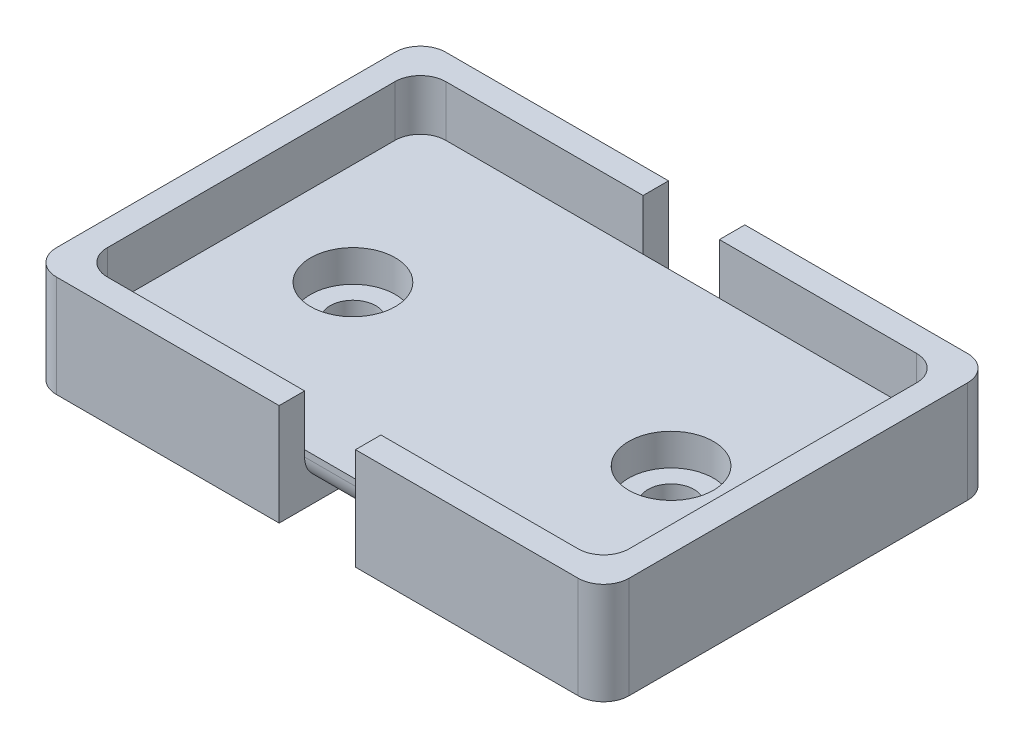
from build123d import *

# Parameters (mm, degrees)
SKETCH1_W           = 22.225
SKETCH1_H           = 33.782
SKETCH1_R           = 4.2291
SKETCH1_R_2         = 2.286
BOSS_EXTRUDE1_DEPTH = 1.905
BOSS_EXTRUDE2_START = 1.905
SKETCH1_3_W         = 22.225
SKETCH1_3_H         = 33.782
SKETCH1_3_R         = 4.2291
SKETCH1_3_W_2       = 7.62
BOSS_EXTRUDE2_DEPTH = 3.175
BOSS_EXTRUDE3_START = 5.08
BOSS_EXTRUDE3_DEPTH = 5.08
FILLET1_R           = 2.54
FILLET2_R           = 2.54


with BuildPart() as part:
    # Sketch1 → Boss-Extrude1 (new body)
    with BuildSketch(Plane(origin=(0, 0, 0), x_dir=(1, 0, 0), z_dir=(0, 1, 0))):
        Polygon((22.225, 36.322), (-2.54, 36.322), (-2.54, -2.54), (22.225, -2.54), (22.225, 0), (0, 0), (0, 33.782), (22.225, 33.782), align=None)
        with Locations((11.1125, 16.891)):
            Rectangle(SKETCH1_W, SKETCH1_H)
        with Locations((10.16, 16.891)):
            Circle(SKETCH1_R, mode=Mode.SUBTRACT)
        with Locations((10.16, 16.891)):
            Circle(SKETCH1_R)
        with Locations((10.16, 16.891)):
            Circle(SKETCH1_R_2, mode=Mode.SUBTRACT)
        with Locations((40.9575, 16.891)):
            Rectangle(SKETCH1_W, SKETCH1_H)
        with Locations((41.91, 16.891)):
            Circle(SKETCH1_R, mode=Mode.SUBTRACT)
        with Locations((41.91, 16.891)):
            Circle(SKETCH1_R)
        with Locations((41.91, 16.891)):
            Circle(SKETCH1_R_2, mode=Mode.SUBTRACT)
        Polygon((54.61, 36.322), (29.845, 36.322), (29.845, 33.782), (52.07, 33.782), (52.07, 0), (29.845, 0), (29.845, -2.54), (54.61, -2.54), align=None)
    extrude(amount=BOSS_EXTRUDE1_DEPTH)

    # Sketch1_3 → Boss-Extrude2 (add)
    with BuildSketch(Plane(origin=(0, 0, 0), x_dir=(1, 0, 0), z_dir=(0, 1, 0)).offset(BOSS_EXTRUDE2_START)):
        with Locations((11.1125, 16.891)):
            Rectangle(SKETCH1_3_W, SKETCH1_3_H)
        with Locations((10.16, 16.891)):
            Circle(SKETCH1_3_R, mode=Mode.SUBTRACT)
        with Locations((40.9575, 16.891)):
            Rectangle(SKETCH1_3_W, SKETCH1_3_H)
        with Locations((41.91, 16.891)):
            Circle(SKETCH1_3_R, mode=Mode.SUBTRACT)
        with Locations((26.035, 16.891)):
            Rectangle(SKETCH1_3_W_2, SKETCH1_3_H)
        Polygon((22.225, 36.322), (-2.54, 36.322), (-2.54, -2.54), (22.225, -2.54), (22.225, 0), (0, 0), (0, 33.782), (22.225, 33.782), align=None)
        Polygon((54.61, 36.322), (29.845, 36.322), (29.845, 33.782), (52.07, 33.782), (52.07, 0), (29.845, 0), (29.845, -2.54), (54.61, -2.54), align=None)
    extrude(amount=BOSS_EXTRUDE2_DEPTH)

    # Sketch1_4 → Boss-Extrude3 (add)
    with BuildSketch(Plane(origin=(0, 0, 0), x_dir=(1, 0, 0), z_dir=(0, 1, 0)).offset(BOSS_EXTRUDE3_START)):
        Polygon((22.225, 36.322), (-2.54, 36.322), (-2.54, -2.54), (22.225, -2.54), (22.225, 0), (0, 0), (0, 33.782), (22.225, 33.782), align=None)
        Polygon((54.61, 36.322), (29.845, 36.322), (29.845, 33.782), (52.07, 33.782), (52.07, 0), (29.845, 0), (29.845, -2.54), (54.61, -2.54), align=None)
    extrude(amount=BOSS_EXTRUDE3_DEPTH)

    # Fillet1
    fillet1_edges = [part.edges().sort_by_distance(p)[0] for p in [
        (-2.54, 5.08, 2.54),
        (-2.54, 5.08, -36.322),
        (54.61, 5.08, 2.54),
        (54.61, 5.08, -36.322),
        (0, 7.62, 0),
        (0, 7.62, -33.782),
        (52.07, 7.62, -33.782),
        (52.07, 7.62, 0),
    ]]
    fillet(fillet1_edges, radius=FILLET1_R)

    # Fillet2
    fillet2_edges = [part.edges().sort_by_distance(p)[0] for p in [
        (26.035, 1.905, -33.782),
        (26.035, 1.905, 0),
    ]]
    fillet(fillet2_edges, radius=FILLET2_R)


solid = part.part
